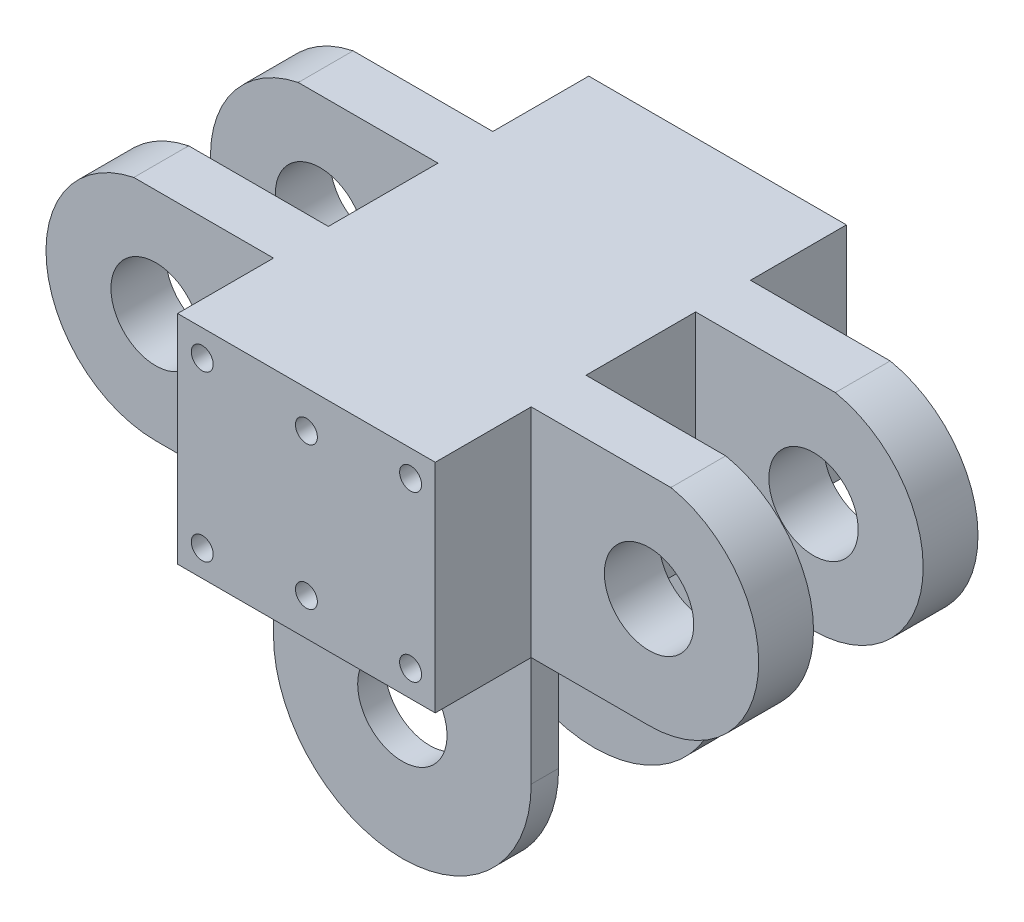
from build123d import *

# Parameters (mm, degrees)
SZKIC1_W                    = 47
SZKIC1_H                    = 39.6
DODANIE_WYCI_GNI_CIE3_DEPTH = 75
SZKIC4_R                    = 8.15
DODANIE_WYCI_GNI_CIE4_DEPTH = 10
SZKIC5_R                    = 8.15
DODANIE_WYCI_GNI_CIE5_DEPTH = 5
SZKIC6_R                    = 2
WYTNIJ_WYCI_GNI_CIE1_DEPTH  = 10


with BuildPart() as part:
    # Szkic1 → Dodanie-wyciągnięcie3 (new body)
    with BuildSketch(Plane.XY):
        with Locations((23.5, 19.8)):
            Rectangle(SZKIC1_W, SZKIC1_H)
    extrude(amount=DODANIE_WYCI_GNI_CIE3_DEPTH)

    # Szkic4 → Dodanie-wyciągnięcie4 (add)
    with BuildSketch(Plane(origin=(0, 0, 27.5), x_dir=(-1, 0, 0), z_dir=(0, 0, -1))):
        with BuildLine():
            Line((-47, 39.6), (-72.479949748, 39.6))
            ThreePointArc((-72.479949748, 39.6), (-88.399748742, 18), (-68.5, 0))
            Line((-68.5, 0), (-47, 0))
            Line((-47, 0), (-47, 39.6))
        make_face()
        with Locations((-68.5, 20)):
            Circle(SZKIC4_R, mode=Mode.SUBTRACT)
        with BuildLine():
            Line((21.5, 0), (0, 0))
            Line((0, 0), (0, 39.6))
            Line((0, 39.6), (25.479949748, 39.6))
            ThreePointArc((25.479949748, 39.6), (41.399748742, 18), (21.5, 0))
        make_face()
        with Locations((21.5, 20)):
            Circle(SZKIC4_R, mode=Mode.SUBTRACT)
    dodanie_wyci_gni_cie4 = extrude(amount=DODANIE_WYCI_GNI_CIE4_DEPTH)

    # Lustro1: Dodanie-wyciągnięcie4 across plane
    add(dodanie_wyci_gni_cie4.mirror(Plane(origin=(0, 0, 37.5), x_dir=(1, 0, 0), z_dir=(0, 0, -1))))

    # Szkic5 → Dodanie-wyciągnięcie5 (add)
    with BuildSketch(Plane(origin=(0, 0, 22.5), x_dir=(-1, 0, 0), z_dir=(0, 0, -1))):
        with BuildLine():
            Line((-47, 0), (0, 0))
            Line((0, 0), (0, -20))
            ThreePointArc((0, -20), (-23.5, -43.5), (-47, -20))
            Line((-47, -20), (-47, 0))
        make_face()
        with Locations((-23.5, -20)):
            Circle(SZKIC5_R, mode=Mode.SUBTRACT)
    dodanie_wyci_gni_cie5 = extrude(amount=DODANIE_WYCI_GNI_CIE5_DEPTH)

    # Lustro2: Dodanie-wyciągnięcie5 across plane
    add(dodanie_wyci_gni_cie5.mirror(Plane(origin=(0, 0, 37.5), x_dir=(1, 0, 0), z_dir=(0, 0, -1))))

    # Szkic6 → Wytnij-wyciągnięcie1 (cut)
    with BuildSketch(Plane.XY.offset(75)):
        with Locations((4.5, 4.8)):
            Circle(SZKIC6_R)
        with Locations((4.5, 34.8)):
            Circle(SZKIC6_R)
        with Locations((42.5, 34.8)):
            Circle(SZKIC6_R)
        with Locations((42.5, 4.8)):
            Circle(SZKIC6_R)
        with Locations((23.5, 32.8)):
            Circle(SZKIC6_R)
        with Locations((23.5, 6.8)):
            Circle(SZKIC6_R)
    extrude(amount=-WYTNIJ_WYCI_GNI_CIE1_DEPTH, mode=Mode.SUBTRACT)


solid = part.part
